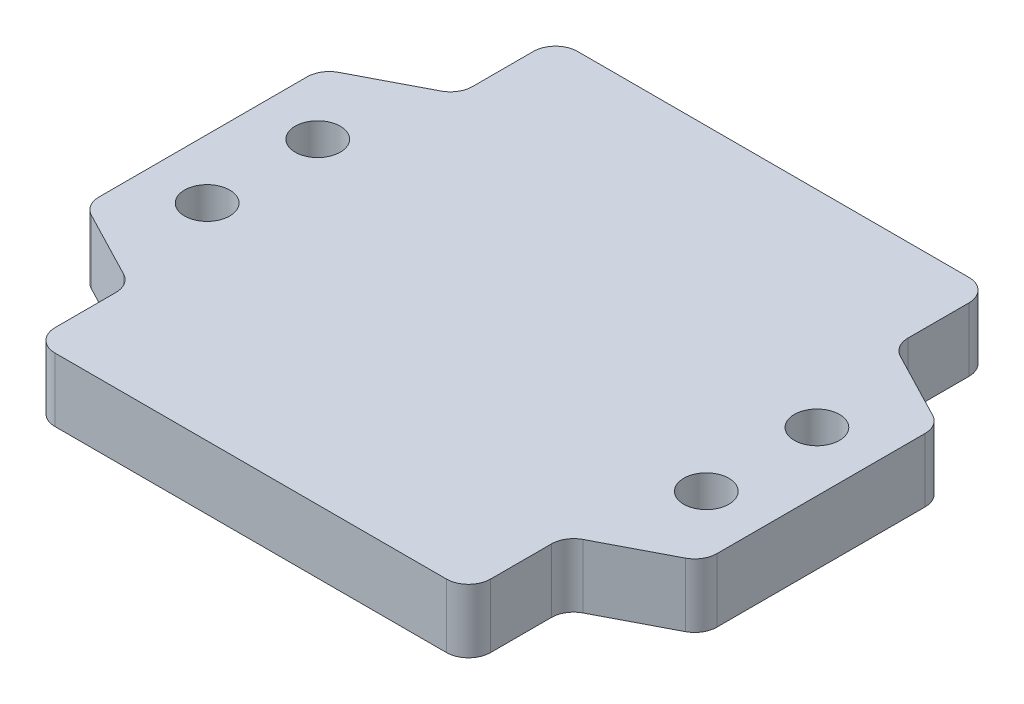
from build123d import *

# Parameters (mm, degrees)
SKETCH1_W                                = 70.945719932
SKETCH1_H                                = 60
BOSS_EXTRUDE1_DEPTH                      = 7.3152
F_6_0_204_DIAMETER_HOLE1_D               = 5.1816
FILLET1_R                                = 2.54
CUT_EXTRUDE1_DEPTH                       = 8.3152
FILLET2_R                                = 2.54
MIRROR4_AT_THE_SECOND_PLANE_COPY_1_DEPTH = 8.3152
FILLET3_R                                = 2.54


with BuildPart() as part:
    # Sketch1 → Boss-Extrude1 (new body)
    with BuildSketch(Plane(origin=(0, 0, 0), x_dir=(1, 0, 0), z_dir=(0, 1, 0))):
        Rectangle(SKETCH1_W, SKETCH1_H)
    extrude(amount=BOSS_EXTRUDE1_DEPTH)

    # 6 _0.204_ Diameter Hole1 (through all)
    with Locations(Plane(origin=(-28.662459966, 7.3152, 6.3474), x_dir=(0, 0, 1), z_dir=(0, 1, 0))):
        with Locations((0, 0), (-12.7, 0)):
            f_6_0_204_diameter_hole1 = Hole(F_6_0_204_DIAMETER_HOLE1_D / 2)

    # Mirror2: 6 _0.204_ Diameter Hole1 across plane
    add(f_6_0_204_diameter_hole1.mirror(Plane(origin=(0, 0, 0), x_dir=(0, 0, 1), z_dir=(1, 0, 0))), mode=Mode.SUBTRACT)

    # Fillet1
    fillet1_edges = [part.edges().sort_by_distance(p)[0] for p in [
        (-35.472859966, 3.6576, -30),
        (35.472859966, 3.6576, -30),
        (35.472859966, 3.6576, 30),
        (-35.472859966, 3.6576, 30),
    ]]
    fillet(fillet1_edges, radius=FILLET1_R)

    # Sketch4 → Cut-Extrude1 (cut, through all)
    with BuildSketch(Plane(origin=(0, 7.3152, 0), x_dir=(1, 0, 0), z_dir=(0, 1, 0))):
        Polygon((-35.472859966, 13.49), (-25.007259027, 18.930947869), (-25.007259027, 30), (-35.472859966, 30), align=None)
    cut_extrude1 = extrude(amount=-CUT_EXTRUDE1_DEPTH, mode=Mode.SUBTRACT)

    # Fillet2
    fillet2_edges = [part.edges().sort_by_distance(p)[0] for p in [
        (-35.472859966, 3.6576, -13.49),
        (-25.007259027, 3.6576, -30),
        (-25.007259027, 3.6576, -18.930947869),
    ]]
    fillet(fillet2_edges, radius=FILLET2_R)

    # Mirror4: Cut-Extrude1 across plane
    add(cut_extrude1.mirror(Plane(origin=(0, 0, 0), x_dir=(0, 0, 1), z_dir=(1, 0, 0))), mode=Mode.SUBTRACT)

    # Mirror4 at the second plane: Cut-Extrude1 across plane
    add(cut_extrude1.mirror(Plane.XY), mode=Mode.SUBTRACT)

    # Mirror4 at the second plane copy 1 sketc → Mirror4 at the second plane copy 1 (cut, through all)
    with BuildSketch(Plane(origin=(0, 7.3152, 0), x_dir=(-1, 0, 0), z_dir=(0, 1, 0))):
        Polygon((-35.472859966, 13.49), (-25.007259027, 18.930947869), (-25.007259027, 30), (-35.472859966, 30), align=None)
    extrude(amount=-MIRROR4_AT_THE_SECOND_PLANE_COPY_1_DEPTH, mode=Mode.SUBTRACT)

    # Fillet3
    fillet3_edges = [part.edges().sort_by_distance(p)[0] for p in [
        (-25.007259027, 3.6576, 30),
        (-35.472859966, 3.6576, 13.49),
        (-25.007259027, 3.6576, 18.930947869),
        (25.007259027, 3.6576, -30),
        (35.472859966, 3.6576, -13.49),
        (25.007259027, 3.6576, -18.930947869),
        (35.472859966, 3.6576, 13.49),
        (25.007259027, 3.6576, 30),
        (25.007259027, 3.6576, 18.930947869),
    ]]
    fillet(fillet3_edges, radius=FILLET3_R)


solid = part.part
